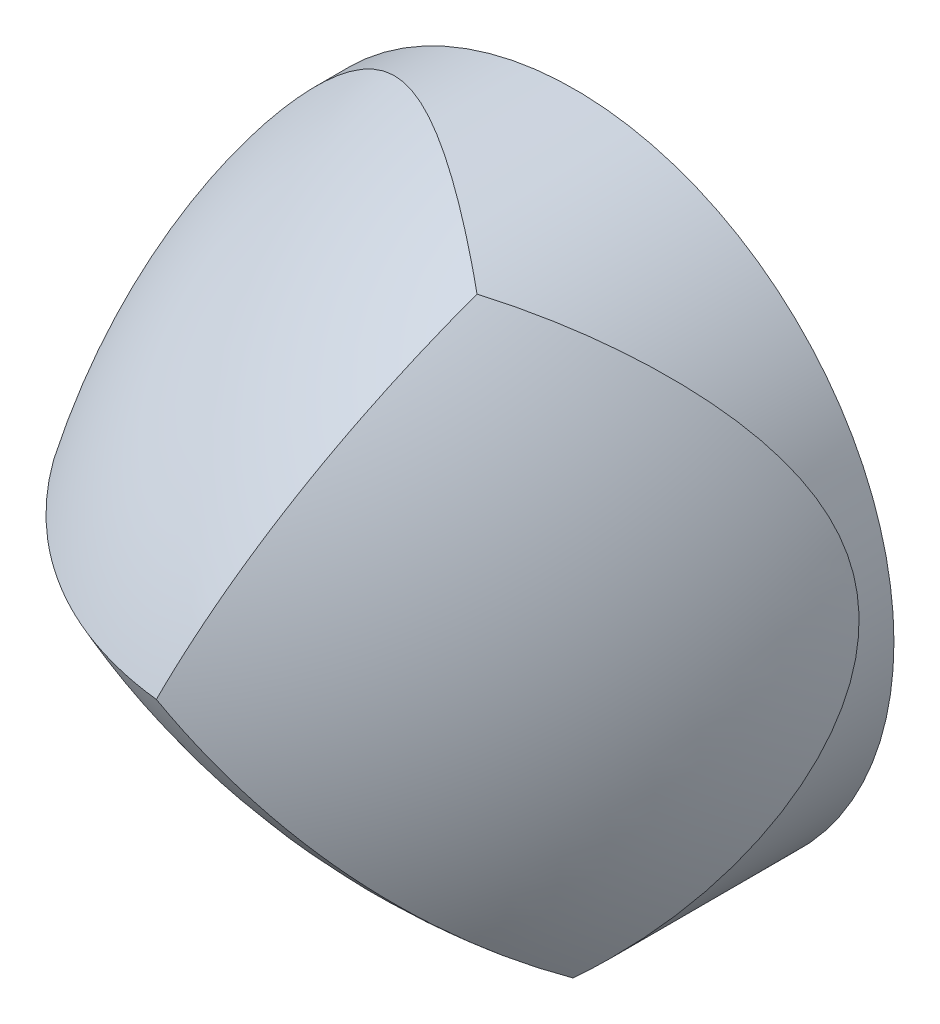
from build123d import *

# Parameters (mm, degrees)
SKETCH1_R           = 152.4
BOSS_EXTRUDE1_DEPTH = 300
CIRPATTERN1_COUNT   = 3


with BuildPart() as part:
    # Sketch1 → Boss-Extrude1 (new body)
    with BuildSketch(Plane.XY):
        Circle(SKETCH1_R)
    extrude(amount=BOSS_EXTRUDE1_DEPTH)

    # Sketch2 → Cut-Revolve1 (revolve, cut)
    with BuildSketch(Plane(origin=(0, 0, -90.9), x_dir=(-0.64278761, 0.766044443, 0), z_dir=(0.766044443, 0.64278761, 0))):
        with BuildLine():
            Line((-144.337567297, -293.6), (-144.337567297, -593.6))
            ThreePointArc((-144.337567297, -593.6), (465.662432703, 16.4), (-144.337567297, 626.4))
            Line((-144.337567297, 626.4), (-144.337567297, 326.4))
            ThreePointArc((-144.337567297, 326.4), (165.662432703, 16.4), (-144.337567297, -293.6))
        make_face()
    cut_revolve1 = revolve(axis=Axis((92.778399871, -110.568991361, -112.7), (0, 0, 1)), mode=Mode.SUBTRACT)

    # CirPattern1: Cut-Revolve1 ×3 about axis
    cirpattern1_axis = Axis((0, 0, 0), (0, 0, 1))
    for i in range(1, CIRPATTERN1_COUNT):
        add(cut_revolve1.rotate(cirpattern1_axis, i * 360 / CIRPATTERN1_COUNT), mode=Mode.SUBTRACT)


solid = part.part
